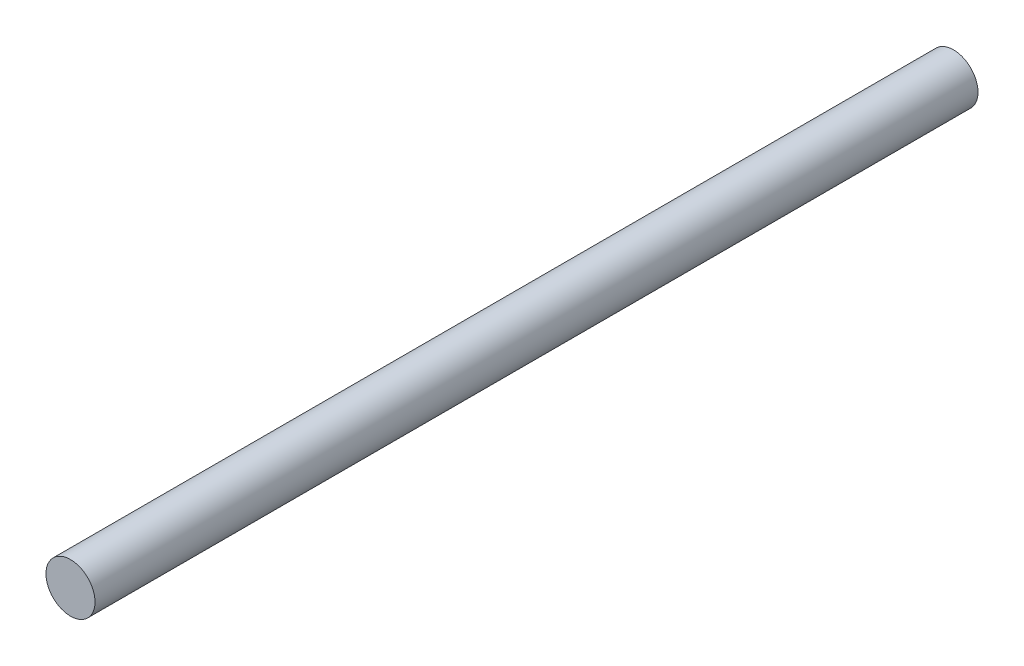
from build123d import *

# Parameters (mm, degrees)
SKETCH_1_R      = 1.25
EXTRUDE_1_DEPTH = 45


with BuildPart() as part:
    # 草图1 → 凸台-拉伸1 (new body)
    with BuildSketch(Plane.XY):
        Circle(SKETCH_1_R)
    extrude(amount=EXTRUDE_1_DEPTH)


solid = part.part
